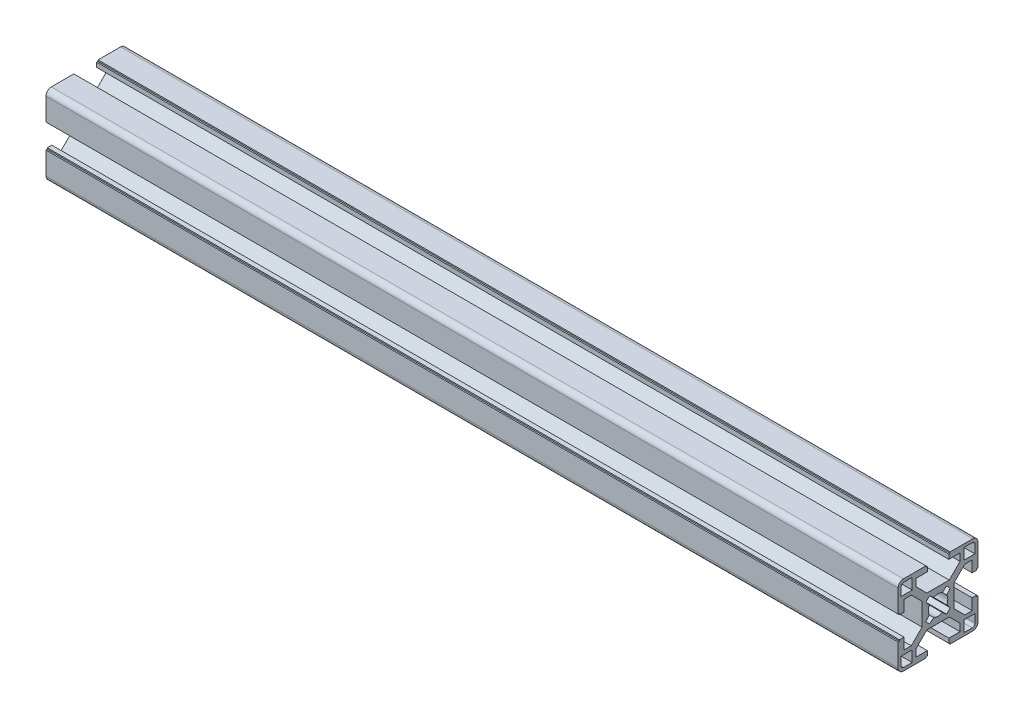
from build123d import *

# Parameters (mm, degrees)
BR_EXTRUDE_DEPTH      = 160
BR_EXTRUDE_DEPTH_BACK = 160


with BuildPart() as part:
    # Sketch2 → BR_Extrude (new body, two sides)
    with BuildSketch(Plane(origin=(0, 0, 0), x_dir=(0, 0, -1), z_dir=(1, 0, 0))) as br_extrude_sk:
        with BuildLine():
            Line((-6, 4.196877708), (-10.053122292, 8.25))
            Line((-10.053122292, 8.25), (-12.8, 8.25))
            Line((-12.8, 8.25), (-12.800036742, 4.05))
            Line((-12.800036742, 4.05), (-14.5, 4.05))
            Line((-14.5, 4.05), (-14.5, 4.55))
            Line((-14.5, 4.55), (-15, 4.55))
            Line((-15, 4.55), (-15, 13))
            ThreePointArc((-15, 13), (-14.414213562, 14.414213562), (-13, 15))
            Line((-13, 15), (-4.55, 15))
            Line((-4.55, 15), (-4.55, 14.5))
            Line((-4.55, 14.5), (-4.05, 14.5))
            Line((-4.05, 14.5), (-4.05, 12.800036742))
            Line((-4.05, 12.800036742), (-8.25, 12.8))
            Line((-8.25, 12.8), (-8.25, 10.053122292))
            Line((-8.25, 10.053122292), (-4.196877708, 6))
            Line((-4.196877708, 6), (4.196877708, 6))
            Line((4.196877708, 6), (8.25, 10.053122292))
            Line((8.25, 10.053122292), (8.25, 12.8))
            Line((8.25, 12.8), (4.05, 12.800036742))
            Line((4.05, 12.800036742), (4.05, 14.5))
            Line((4.05, 14.5), (4.55, 14.5))
            Line((4.55, 14.5), (4.55, 15))
            Line((4.55, 15), (13, 15))
            ThreePointArc((13, 15), (14.414213562, 14.414213562), (15, 13))
            Line((15, 13), (15, 4.55))
            Line((15, 4.55), (14.5, 4.55))
            Line((14.5, 4.55), (14.5, 4.05))
            Line((14.5, 4.05), (12.800036742, 4.05))
            Line((12.800036742, 4.05), (12.8, 8.25))
            Line((12.8, 8.25), (10.053122292, 8.25))
            Line((10.053122292, 8.25), (6, 4.196877708))
            Line((6, 4.196877708), (6, -4.196877708))
            Line((6, -4.196877708), (10.053122292, -8.25))
            Line((10.053122292, -8.25), (12.8, -8.25))
            Line((12.8, -8.25), (12.800036742, -4.05))
            Line((12.800036742, -4.05), (14.5, -4.05))
            Line((14.5, -4.05), (14.5, -4.55))
            Line((14.5, -4.55), (15, -4.55))
            Line((15, -4.55), (15, -13))
            ThreePointArc((15, -13), (14.414213562, -14.414213562), (13, -15))
            Line((13, -15), (4.55, -15))
            Line((4.55, -15), (4.55, -14.5))
            Line((4.55, -14.5), (4.05, -14.5))
            Line((4.05, -14.5), (4.05, -12.800036742))
            Line((4.05, -12.800036742), (8.25, -12.8))
            Line((8.25, -12.8), (8.25, -10.053122292))
            Line((8.25, -10.053122292), (4.196877708, -6))
            Line((4.196877708, -6), (-4.196877708, -6))
            Line((-4.196877708, -6), (-8.25, -10.053122292))
            Line((-8.25, -10.053122292), (-8.25, -12.8))
            Line((-8.25, -12.8), (-4.05, -12.800036742))
            Line((-4.05, -12.800036742), (-4.05, -14.5))
            Line((-4.05, -14.5), (-4.55, -14.5))
            Line((-4.55, -14.5), (-4.55, -15))
            Line((-4.55, -15), (-13, -15))
            ThreePointArc((-13, -15), (-14.414213562, -14.414213562), (-15, -13))
            Line((-15, -13), (-15, -4.55))
            Line((-15, -4.55), (-14.5, -4.55))
            Line((-14.5, -4.55), (-14.5, -4.05))
            Line((-14.5, -4.05), (-12.800036742, -4.05))
            Line((-12.800036742, -4.05), (-12.8, -8.25))
            Line((-12.8, -8.25), (-10.053122292, -8.25))
            Line((-10.053122292, -8.25), (-6, -4.196877708))
            Line((-6, -4.196877708), (-6, 4.196877708))
        make_face()
        with BuildLine():
            Line((-13.85, -9.7), (-13.85, -12.85))
            ThreePointArc((-13.85, -12.85), (-13.557106781, -13.557106781), (-12.85, -13.85))
            Line((-12.85, -13.85), (-9.7, -13.85))
            Line((-9.7, -13.85), (-9.7, -9.7))
            Line((-9.7, -9.7), (-13.85, -9.7))
        make_face(mode=Mode.SUBTRACT)
        with BuildLine():
            Line((9.7, -13.85), (12.85, -13.85))
            ThreePointArc((12.85, -13.85), (13.557106781, -13.557106781), (13.85, -12.85))
            Line((13.85, -12.85), (13.85, -9.7))
            Line((13.85, -9.7), (9.7, -9.7))
            Line((9.7, -9.7), (9.7, -13.85))
        make_face(mode=Mode.SUBTRACT)
        with BuildLine():
            Line((13.85, 9.7), (13.85, 12.85))
            ThreePointArc((13.85, 12.85), (13.557106781, 13.557106781), (12.85, 13.85))
            Line((12.85, 13.85), (9.7, 13.85))
            Line((9.7, 13.85), (9.7, 9.7))
            Line((9.7, 9.7), (13.85, 9.7))
        make_face(mode=Mode.SUBTRACT)
        with BuildLine():
            Line((-9.7, 13.85), (-12.85, 13.85))
            ThreePointArc((-12.85, 13.85), (-13.557106781, 13.557106781), (-13.85, 12.85))
            Line((-13.85, 12.85), (-13.85, 9.7))
            Line((-13.85, 9.7), (-9.7, 9.7))
            Line((-9.7, 9.7), (-9.7, 13.85))
        make_face(mode=Mode.SUBTRACT)
        with BuildLine():
            Line((-3.272394192, -1.616767223), (-4.59052283, -3.187651763))
            Line((-4.59052283, -3.187651763), (-3.187651763, -4.59052283))
            Line((-3.187651763, -4.59052283), (-1.616767223, -3.272394192))
            ThreePointArc((-1.616767223, -3.272394192), (0, -3.65), (1.616767223, -3.272394192))
            Line((1.616767223, -3.272394192), (3.187651763, -4.59052283))
            Line((3.187651763, -4.59052283), (4.59052283, -3.187651763))
            Line((4.59052283, -3.187651763), (3.272394192, -1.616767223))
            ThreePointArc((3.272394192, -1.616767223), (3.65, 0), (3.272394192, 1.616767223))
            Line((3.272394192, 1.616767223), (4.59052283, 3.187651763))
            Line((4.59052283, 3.187651763), (3.187651763, 4.59052283))
            Line((3.187651763, 4.59052283), (1.616767223, 3.272394192))
            ThreePointArc((1.616767223, 3.272394192), (0, 3.65), (-1.616767223, 3.272394192))
            Line((-1.616767223, 3.272394192), (-3.187651763, 4.59052283))
            Line((-3.187651763, 4.59052283), (-4.59052283, 3.187651763))
            Line((-4.59052283, 3.187651763), (-3.272394192, 1.616767223))
            ThreePointArc((-3.272394192, 1.616767223), (-3.65, 0), (-3.272394192, -1.616767223))
        make_face(mode=Mode.SUBTRACT)
    extrude(amount=BR_EXTRUDE_DEPTH)
    extrude(br_extrude_sk.sketch, amount=-BR_EXTRUDE_DEPTH_BACK)


solid = part.part
